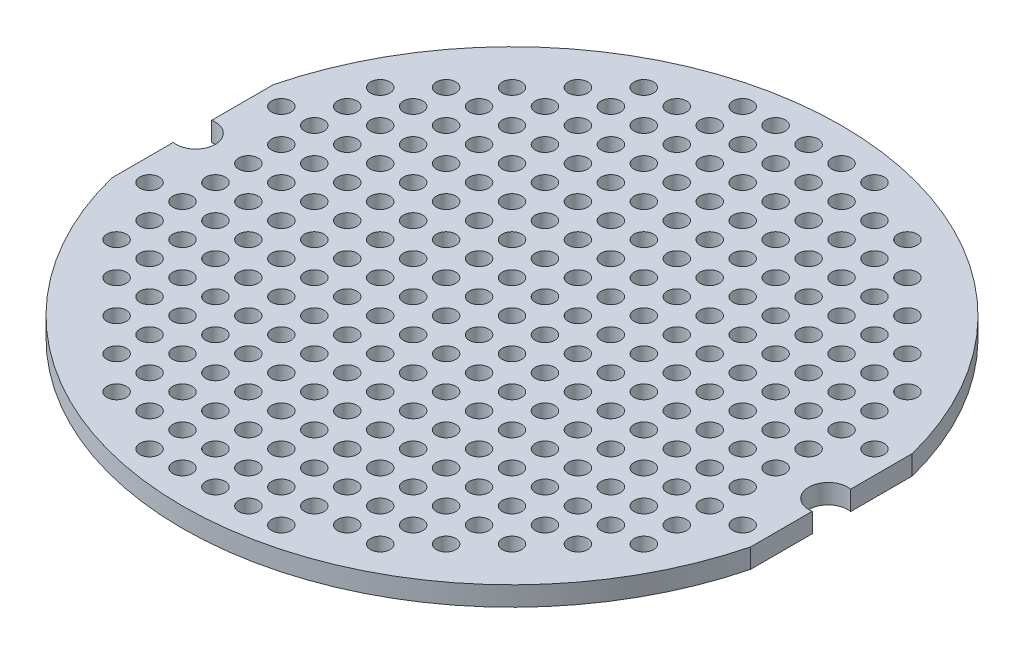
from build123d import *

# Parameters (mm, degrees)
SKETCH_1_R          = 25.4
EXTRUDE_1_DEPTH     = 1.5
CUT_EXTRUDE_1_DEPTH = 2.5
SKETCH_3_R          = 0.75
CUT_EXTRUDE_2_DEPTH = 2.5


with BuildPart() as part:
    # ｽｹｯﾁ1 → ﾎﾞｽ - 押し出し1 (new body)
    with BuildSketch(Plane(origin=(0, 0, 0), x_dir=(1, 0, 0), z_dir=(0, 1, 0))):
        Circle(SKETCH_1_R)
    extrude(amount=EXTRUDE_1_DEPTH)

    # ｽｹｯﾁ2 → ｶｯﾄ - 押し出し1 (cut, through all)
    with BuildSketch(Plane(origin=(0, 1.5, 0), x_dir=(1, 0, 0), z_dir=(0, 1, 0))):
        with BuildLine():
            Line((-24.625, 6.226505842), (-24.625, 1.479019946))
            ThreePointArc((-24.625, 1.479019946), (-22.875, 0), (-24.625, -1.479019946))
            Line((-24.625, -1.479019946), (-24.625, -6.226505842))
            ThreePointArc((-24.625, -6.226505842), (-25.4, 0), (-24.625, 6.226505842))
        make_face()
        with BuildLine():
            Line((24.625, 6.226505842), (24.625, 1.479019946))
            ThreePointArc((24.625, 1.479019946), (22.875, 0), (24.625, -1.479019946))
            Line((24.625, -1.479019946), (24.625, -6.226505842))
            ThreePointArc((24.625, -6.226505842), (25.130359437, -3.691210447), (25.375397436, -1.117678384))
            ThreePointArc((25.375397436, -1.117678384), (25.875, 0), (25.375397436, 1.117678384))
            ThreePointArc((25.375397436, 1.117678384), (25.130359437, 3.691210447), (24.625, 6.226505842))
        make_face()
    extrude(amount=-CUT_EXTRUDE_1_DEPTH, mode=Mode.SUBTRACT)

    # ｽｹｯﾁ3 → ｶｯﾄ - 押し出し2 (cut, through all)
    with BuildSketch(Plane(origin=(0, 1.5, 0), x_dir=(1, 0, 0), z_dir=(0, 1, 0))):
        with Locations((-5.08, -22.86)):
            Circle(SKETCH_3_R)
        with Locations((-2.54, -22.86)):
            Circle(SKETCH_3_R)
        Circle(SKETCH_3_R)
        with Locations((2.54, 0)):
            Circle(SKETCH_3_R)
        with Locations((5.08, 0)):
            Circle(SKETCH_3_R)
        with Locations((7.62, 0)):
            Circle(SKETCH_3_R)
        with Locations((10.16, 0)):
            Circle(SKETCH_3_R)
        with Locations((12.7, 0)):
            Circle(SKETCH_3_R)
        with Locations((15.24, 0)):
            Circle(SKETCH_3_R)
        with Locations((17.78, 0)):
            Circle(SKETCH_3_R)
        with Locations((20.32, 0)):
            Circle(SKETCH_3_R)
        with Locations((2.54, -2.54)):
            Circle(SKETCH_3_R)
        with Locations((5.08, -2.54)):
            Circle(SKETCH_3_R)
        with Locations((7.62, -2.54)):
            Circle(SKETCH_3_R)
        with Locations((10.16, -2.54)):
            Circle(SKETCH_3_R)
        with Locations((12.7, -2.54)):
            Circle(SKETCH_3_R)
        with Locations((15.24, -2.54)):
            Circle(SKETCH_3_R)
        with Locations((17.78, -2.54)):
            Circle(SKETCH_3_R)
        with Locations((20.32, -2.54)):
            Circle(SKETCH_3_R)
        with Locations((2.54, -5.08)):
            Circle(SKETCH_3_R)
        with Locations((5.08, -5.08)):
            Circle(SKETCH_3_R)
        with Locations((7.62, -5.08)):
            Circle(SKETCH_3_R)
        with Locations((10.16, -5.08)):
            Circle(SKETCH_3_R)
        with Locations((12.7, -5.08)):
            Circle(SKETCH_3_R)
        with Locations((15.24, -5.08)):
            Circle(SKETCH_3_R)
        with Locations((17.78, -5.08)):
            Circle(SKETCH_3_R)
        with Locations((20.32, -5.08)):
            Circle(SKETCH_3_R)
        with Locations((22.86, -5.08)):
            Circle(SKETCH_3_R)
        with Locations((2.54, -7.62)):
            Circle(SKETCH_3_R)
        with Locations((5.08, -7.62)):
            Circle(SKETCH_3_R)
        with Locations((7.62, -7.62)):
            Circle(SKETCH_3_R)
        with Locations((10.16, -7.62)):
            Circle(SKETCH_3_R)
        with Locations((12.7, -7.62)):
            Circle(SKETCH_3_R)
        with Locations((15.24, -7.62)):
            Circle(SKETCH_3_R)
        with Locations((17.78, -7.62)):
            Circle(SKETCH_3_R)
        with Locations((20.32, -7.62)):
            Circle(SKETCH_3_R)
        with Locations((2.54, -10.16)):
            Circle(SKETCH_3_R)
        with Locations((5.08, -10.16)):
            Circle(SKETCH_3_R)
        with Locations((7.62, -10.16)):
            Circle(SKETCH_3_R)
        with Locations((10.16, -10.16)):
            Circle(SKETCH_3_R)
        with Locations((12.7, -10.16)):
            Circle(SKETCH_3_R)
        with Locations((15.24, -10.16)):
            Circle(SKETCH_3_R)
        with Locations((17.78, -10.16)):
            Circle(SKETCH_3_R)
        with Locations((20.32, -10.16)):
            Circle(SKETCH_3_R)
        with Locations((2.54, -12.7)):
            Circle(SKETCH_3_R)
        with Locations((5.08, -12.7)):
            Circle(SKETCH_3_R)
        with Locations((7.62, -12.7)):
            Circle(SKETCH_3_R)
        with Locations((10.16, -12.7)):
            Circle(SKETCH_3_R)
        with Locations((12.7, -12.7)):
            Circle(SKETCH_3_R)
        with Locations((15.24, -12.7)):
            Circle(SKETCH_3_R)
        with Locations((17.78, -12.7)):
            Circle(SKETCH_3_R)
        with Locations((2.54, -15.24)):
            Circle(SKETCH_3_R)
        with Locations((5.08, -15.24)):
            Circle(SKETCH_3_R)
        with Locations((7.62, -15.24)):
            Circle(SKETCH_3_R)
        with Locations((10.16, -15.24)):
            Circle(SKETCH_3_R)
        with Locations((12.7, -15.24)):
            Circle(SKETCH_3_R)
        with Locations((15.24, -15.24)):
            Circle(SKETCH_3_R)
        with Locations((2.54, -17.78)):
            Circle(SKETCH_3_R)
        with Locations((5.08, -17.78)):
            Circle(SKETCH_3_R)
        with Locations((7.62, -17.78)):
            Circle(SKETCH_3_R)
        with Locations((10.16, -17.78)):
            Circle(SKETCH_3_R)
        with Locations((12.7, -17.78)):
            Circle(SKETCH_3_R)
        with Locations((2.54, -20.32)):
            Circle(SKETCH_3_R)
        with Locations((5.08, -20.32)):
            Circle(SKETCH_3_R)
        with Locations((7.62, -20.32)):
            Circle(SKETCH_3_R)
        with Locations((10.16, -20.32)):
            Circle(SKETCH_3_R)
        with Locations((2.54, -22.86)):
            Circle(SKETCH_3_R)
        with Locations((5.08, -22.86)):
            Circle(SKETCH_3_R)
        with Locations((0, -2.54)):
            Circle(SKETCH_3_R)
        with Locations((0, -5.08)):
            Circle(SKETCH_3_R)
        with Locations((0, -7.62)):
            Circle(SKETCH_3_R)
        with Locations((0, -10.16)):
            Circle(SKETCH_3_R)
        with Locations((0, -12.7)):
            Circle(SKETCH_3_R)
        with Locations((0, -15.24)):
            Circle(SKETCH_3_R)
        with Locations((0, -17.78)):
            Circle(SKETCH_3_R)
        with Locations((0, -20.32)):
            Circle(SKETCH_3_R)
        with Locations((0, -22.86)):
            Circle(SKETCH_3_R)
        with Locations((-10.16, -20.32)):
            Circle(SKETCH_3_R)
        with Locations((-7.62, -20.32)):
            Circle(SKETCH_3_R)
        with Locations((-5.08, -20.32)):
            Circle(SKETCH_3_R)
        with Locations((-2.54, -20.32)):
            Circle(SKETCH_3_R)
        with Locations((-12.7, -17.78)):
            Circle(SKETCH_3_R)
        with Locations((-10.16, -17.78)):
            Circle(SKETCH_3_R)
        with Locations((-7.62, -17.78)):
            Circle(SKETCH_3_R)
        with Locations((-5.08, -17.78)):
            Circle(SKETCH_3_R)
        with Locations((-2.54, -17.78)):
            Circle(SKETCH_3_R)
        with Locations((-15.24, -15.24)):
            Circle(SKETCH_3_R)
        with Locations((-12.7, -15.24)):
            Circle(SKETCH_3_R)
        with Locations((-10.16, -15.24)):
            Circle(SKETCH_3_R)
        with Locations((-7.62, -15.24)):
            Circle(SKETCH_3_R)
        with Locations((-5.08, -15.24)):
            Circle(SKETCH_3_R)
        with Locations((-2.54, -15.24)):
            Circle(SKETCH_3_R)
        with Locations((-17.78, -12.7)):
            Circle(SKETCH_3_R)
        with Locations((-15.24, -12.7)):
            Circle(SKETCH_3_R)
        with Locations((-12.7, -12.7)):
            Circle(SKETCH_3_R)
        with Locations((-10.16, -12.7)):
            Circle(SKETCH_3_R)
        with Locations((-7.62, -12.7)):
            Circle(SKETCH_3_R)
        with Locations((-5.08, -12.7)):
            Circle(SKETCH_3_R)
        with Locations((-2.54, -12.7)):
            Circle(SKETCH_3_R)
        with Locations((-20.32, -10.16)):
            Circle(SKETCH_3_R)
        with Locations((-17.78, -10.16)):
            Circle(SKETCH_3_R)
        with Locations((-15.24, -10.16)):
            Circle(SKETCH_3_R)
        with Locations((-12.7, -10.16)):
            Circle(SKETCH_3_R)
        with Locations((-10.16, -10.16)):
            Circle(SKETCH_3_R)
        with Locations((-7.62, -10.16)):
            Circle(SKETCH_3_R)
        with Locations((-5.08, -10.16)):
            Circle(SKETCH_3_R)
        with Locations((-2.54, -10.16)):
            Circle(SKETCH_3_R)
        with Locations((-20.32, -7.62)):
            Circle(SKETCH_3_R)
        with Locations((-17.78, -7.62)):
            Circle(SKETCH_3_R)
        with Locations((-15.24, -7.62)):
            Circle(SKETCH_3_R)
        with Locations((-12.7, -7.62)):
            Circle(SKETCH_3_R)
        with Locations((-10.16, -7.62)):
            Circle(SKETCH_3_R)
        with Locations((-7.62, -7.62)):
            Circle(SKETCH_3_R)
        with Locations((-5.08, -7.62)):
            Circle(SKETCH_3_R)
        with Locations((-2.54, -7.62)):
            Circle(SKETCH_3_R)
        with Locations((-22.86, -5.08)):
            Circle(SKETCH_3_R)
        with Locations((-20.32, -5.08)):
            Circle(SKETCH_3_R)
        with Locations((-17.78, -5.08)):
            Circle(SKETCH_3_R)
        with Locations((-15.24, -5.08)):
            Circle(SKETCH_3_R)
        with Locations((-12.7, -5.08)):
            Circle(SKETCH_3_R)
        with Locations((-10.16, -5.08)):
            Circle(SKETCH_3_R)
        with Locations((-7.62, -5.08)):
            Circle(SKETCH_3_R)
        with Locations((-5.08, -5.08)):
            Circle(SKETCH_3_R)
        with Locations((-2.54, -5.08)):
            Circle(SKETCH_3_R)
        with Locations((-20.32, -2.54)):
            Circle(SKETCH_3_R)
        with Locations((-17.78, -2.54)):
            Circle(SKETCH_3_R)
        with Locations((-15.24, -2.54)):
            Circle(SKETCH_3_R)
        with Locations((-12.7, -2.54)):
            Circle(SKETCH_3_R)
        with Locations((-10.16, -2.54)):
            Circle(SKETCH_3_R)
        with Locations((-7.62, -2.54)):
            Circle(SKETCH_3_R)
        with Locations((-5.08, -2.54)):
            Circle(SKETCH_3_R)
        with Locations((-2.54, -2.54)):
            Circle(SKETCH_3_R)
        with Locations((-20.32, 0)):
            Circle(SKETCH_3_R)
        with Locations((-17.78, 0)):
            Circle(SKETCH_3_R)
        with Locations((-15.24, 0)):
            Circle(SKETCH_3_R)
        with Locations((-12.7, 0)):
            Circle(SKETCH_3_R)
        with Locations((-10.16, 0)):
            Circle(SKETCH_3_R)
        with Locations((-7.62, 0)):
            Circle(SKETCH_3_R)
        with Locations((-5.08, 0)):
            Circle(SKETCH_3_R)
        with Locations((-2.54, 0)):
            Circle(SKETCH_3_R)
        with Locations((-2.54, 2.54)):
            Circle(SKETCH_3_R)
        with Locations((-5.08, 2.54)):
            Circle(SKETCH_3_R)
        with Locations((-7.62, 2.54)):
            Circle(SKETCH_3_R)
        with Locations((-10.16, 2.54)):
            Circle(SKETCH_3_R)
        with Locations((-12.7, 2.54)):
            Circle(SKETCH_3_R)
        with Locations((-15.24, 2.54)):
            Circle(SKETCH_3_R)
        with Locations((-17.78, 2.54)):
            Circle(SKETCH_3_R)
        with Locations((-20.32, 2.54)):
            Circle(SKETCH_3_R)
        with Locations((-2.54, 5.08)):
            Circle(SKETCH_3_R)
        with Locations((-5.08, 5.08)):
            Circle(SKETCH_3_R)
        with Locations((-7.62, 5.08)):
            Circle(SKETCH_3_R)
        with Locations((-10.16, 5.08)):
            Circle(SKETCH_3_R)
        with Locations((-12.7, 5.08)):
            Circle(SKETCH_3_R)
        with Locations((-15.24, 5.08)):
            Circle(SKETCH_3_R)
        with Locations((-17.78, 5.08)):
            Circle(SKETCH_3_R)
        with Locations((-20.32, 5.08)):
            Circle(SKETCH_3_R)
        with Locations((-22.86, 5.08)):
            Circle(SKETCH_3_R)
        with Locations((-2.54, 7.62)):
            Circle(SKETCH_3_R)
        with Locations((-5.08, 7.62)):
            Circle(SKETCH_3_R)
        with Locations((-7.62, 7.62)):
            Circle(SKETCH_3_R)
        with Locations((-10.16, 7.62)):
            Circle(SKETCH_3_R)
        with Locations((-12.7, 7.62)):
            Circle(SKETCH_3_R)
        with Locations((-15.24, 7.62)):
            Circle(SKETCH_3_R)
        with Locations((-17.78, 7.62)):
            Circle(SKETCH_3_R)
        with Locations((-20.32, 7.62)):
            Circle(SKETCH_3_R)
        with Locations((-2.54, 10.16)):
            Circle(SKETCH_3_R)
        with Locations((-5.08, 10.16)):
            Circle(SKETCH_3_R)
        with Locations((-7.62, 10.16)):
            Circle(SKETCH_3_R)
        with Locations((-10.16, 10.16)):
            Circle(SKETCH_3_R)
        with Locations((-12.7, 10.16)):
            Circle(SKETCH_3_R)
        with Locations((-15.24, 10.16)):
            Circle(SKETCH_3_R)
        with Locations((-17.78, 10.16)):
            Circle(SKETCH_3_R)
        with Locations((-20.32, 10.16)):
            Circle(SKETCH_3_R)
        with Locations((-2.54, 12.7)):
            Circle(SKETCH_3_R)
        with Locations((-5.08, 12.7)):
            Circle(SKETCH_3_R)
        with Locations((-7.62, 12.7)):
            Circle(SKETCH_3_R)
        with Locations((-10.16, 12.7)):
            Circle(SKETCH_3_R)
        with Locations((-12.7, 12.7)):
            Circle(SKETCH_3_R)
        with Locations((-15.24, 12.7)):
            Circle(SKETCH_3_R)
        with Locations((-17.78, 12.7)):
            Circle(SKETCH_3_R)
        with Locations((-2.54, 15.24)):
            Circle(SKETCH_3_R)
        with Locations((-5.08, 15.24)):
            Circle(SKETCH_3_R)
        with Locations((-7.62, 15.24)):
            Circle(SKETCH_3_R)
        with Locations((-10.16, 15.24)):
            Circle(SKETCH_3_R)
        with Locations((-12.7, 15.24)):
            Circle(SKETCH_3_R)
        with Locations((-15.24, 15.24)):
            Circle(SKETCH_3_R)
        with Locations((-2.54, 17.78)):
            Circle(SKETCH_3_R)
        with Locations((-5.08, 17.78)):
            Circle(SKETCH_3_R)
        with Locations((-7.62, 17.78)):
            Circle(SKETCH_3_R)
        with Locations((-10.16, 17.78)):
            Circle(SKETCH_3_R)
        with Locations((-12.7, 17.78)):
            Circle(SKETCH_3_R)
        with Locations((-2.54, 20.32)):
            Circle(SKETCH_3_R)
        with Locations((-5.08, 20.32)):
            Circle(SKETCH_3_R)
        with Locations((-7.62, 20.32)):
            Circle(SKETCH_3_R)
        with Locations((-10.16, 20.32)):
            Circle(SKETCH_3_R)
        with Locations((0, 22.86)):
            Circle(SKETCH_3_R)
        with Locations((0, 20.32)):
            Circle(SKETCH_3_R)
        with Locations((0, 17.78)):
            Circle(SKETCH_3_R)
        with Locations((0, 15.24)):
            Circle(SKETCH_3_R)
        with Locations((0, 12.7)):
            Circle(SKETCH_3_R)
        with Locations((0, 10.16)):
            Circle(SKETCH_3_R)
        with Locations((0, 7.62)):
            Circle(SKETCH_3_R)
        with Locations((0, 5.08)):
            Circle(SKETCH_3_R)
        with Locations((0, 2.54)):
            Circle(SKETCH_3_R)
        with Locations((5.08, 22.86)):
            Circle(SKETCH_3_R)
        with Locations((2.54, 22.86)):
            Circle(SKETCH_3_R)
        with Locations((10.16, 20.32)):
            Circle(SKETCH_3_R)
        with Locations((7.62, 20.32)):
            Circle(SKETCH_3_R)
        with Locations((5.08, 20.32)):
            Circle(SKETCH_3_R)
        with Locations((2.54, 20.32)):
            Circle(SKETCH_3_R)
        with Locations((12.7, 17.78)):
            Circle(SKETCH_3_R)
        with Locations((10.16, 17.78)):
            Circle(SKETCH_3_R)
        with Locations((7.62, 17.78)):
            Circle(SKETCH_3_R)
        with Locations((5.08, 17.78)):
            Circle(SKETCH_3_R)
        with Locations((2.54, 17.78)):
            Circle(SKETCH_3_R)
        with Locations((15.24, 15.24)):
            Circle(SKETCH_3_R)
        with Locations((12.7, 15.24)):
            Circle(SKETCH_3_R)
        with Locations((10.16, 15.24)):
            Circle(SKETCH_3_R)
        with Locations((7.62, 15.24)):
            Circle(SKETCH_3_R)
        with Locations((5.08, 15.24)):
            Circle(SKETCH_3_R)
        with Locations((2.54, 15.24)):
            Circle(SKETCH_3_R)
        with Locations((17.78, 12.7)):
            Circle(SKETCH_3_R)
        with Locations((15.24, 12.7)):
            Circle(SKETCH_3_R)
        with Locations((12.7, 12.7)):
            Circle(SKETCH_3_R)
        with Locations((10.16, 12.7)):
            Circle(SKETCH_3_R)
        with Locations((7.62, 12.7)):
            Circle(SKETCH_3_R)
        with Locations((5.08, 12.7)):
            Circle(SKETCH_3_R)
        with Locations((2.54, 12.7)):
            Circle(SKETCH_3_R)
        with Locations((20.32, 10.16)):
            Circle(SKETCH_3_R)
        with Locations((17.78, 10.16)):
            Circle(SKETCH_3_R)
        with Locations((15.24, 10.16)):
            Circle(SKETCH_3_R)
        with Locations((12.7, 10.16)):
            Circle(SKETCH_3_R)
        with Locations((10.16, 10.16)):
            Circle(SKETCH_3_R)
        with Locations((7.62, 10.16)):
            Circle(SKETCH_3_R)
        with Locations((5.08, 10.16)):
            Circle(SKETCH_3_R)
        with Locations((2.54, 10.16)):
            Circle(SKETCH_3_R)
        with Locations((20.32, 7.62)):
            Circle(SKETCH_3_R)
        with Locations((17.78, 7.62)):
            Circle(SKETCH_3_R)
        with Locations((15.24, 7.62)):
            Circle(SKETCH_3_R)
        with Locations((12.7, 7.62)):
            Circle(SKETCH_3_R)
        with Locations((10.16, 7.62)):
            Circle(SKETCH_3_R)
        with Locations((7.62, 7.62)):
            Circle(SKETCH_3_R)
        with Locations((5.08, 7.62)):
            Circle(SKETCH_3_R)
        with Locations((2.54, 7.62)):
            Circle(SKETCH_3_R)
        with Locations((22.86, 5.08)):
            Circle(SKETCH_3_R)
        with Locations((20.32, 5.08)):
            Circle(SKETCH_3_R)
        with Locations((17.78, 5.08)):
            Circle(SKETCH_3_R)
        with Locations((15.24, 5.08)):
            Circle(SKETCH_3_R)
        with Locations((12.7, 5.08)):
            Circle(SKETCH_3_R)
        with Locations((10.16, 5.08)):
            Circle(SKETCH_3_R)
        with Locations((7.62, 5.08)):
            Circle(SKETCH_3_R)
        with Locations((5.08, 5.08)):
            Circle(SKETCH_3_R)
        with Locations((2.54, 5.08)):
            Circle(SKETCH_3_R)
        with Locations((20.32, 2.54)):
            Circle(SKETCH_3_R)
        with Locations((17.78, 2.54)):
            Circle(SKETCH_3_R)
        with Locations((15.24, 2.54)):
            Circle(SKETCH_3_R)
        with Locations((12.7, 2.54)):
            Circle(SKETCH_3_R)
        with Locations((10.16, 2.54)):
            Circle(SKETCH_3_R)
        with Locations((7.62, 2.54)):
            Circle(SKETCH_3_R)
        with Locations((5.08, 2.54)):
            Circle(SKETCH_3_R)
        with Locations((2.54, 2.54)):
            Circle(SKETCH_3_R)
        with Locations((-2.54, 22.86)):
            Circle(SKETCH_3_R)
        with Locations((-5.08, 22.86)):
            Circle(SKETCH_3_R)
    extrude(amount=-CUT_EXTRUDE_2_DEPTH, mode=Mode.SUBTRACT)


solid = part.part
